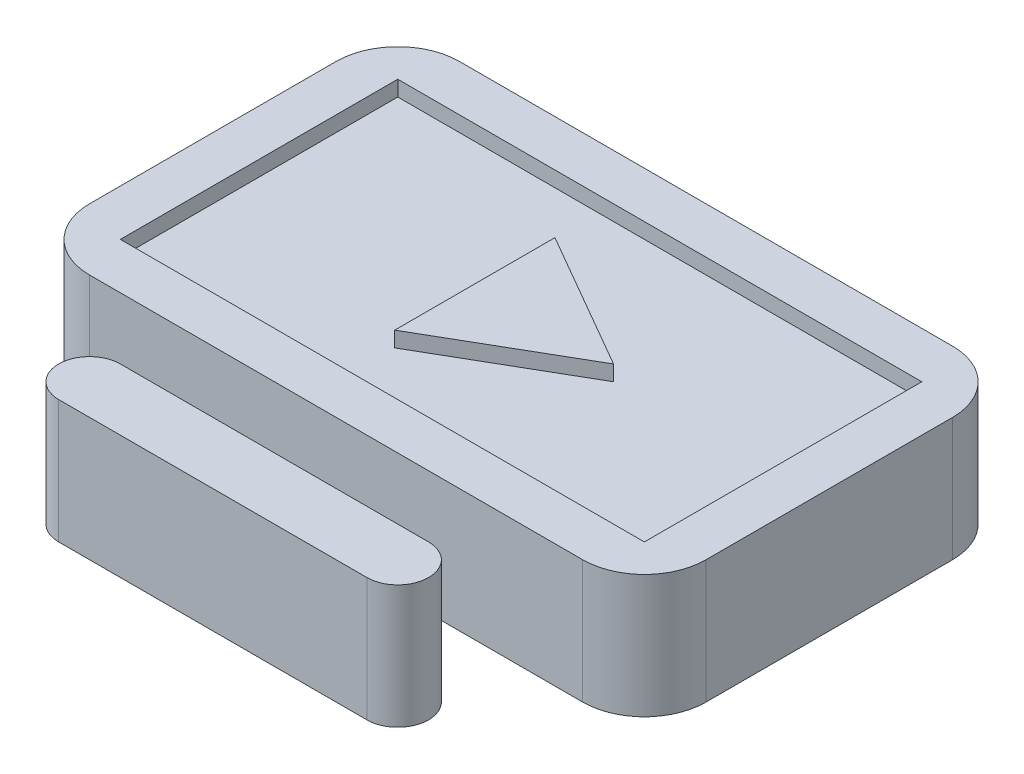
from build123d import *

# Parameters (mm, degrees)
BOSS_EXTRUDE1_DEPTH = 50.8
FILLET1_R           = 25.4
SKETCH4_W           = 215.9
SKETCH4_H           = 114.3
CUT_EXTRUDE1_DEPTH  = 6.35
BOSS_EXTRUDE2_DEPTH = 6.35
SKETCH6_W           = 25.4
SKETCH6_H           = 25.4
CUT_EXTRUDE2_DEPTH  = 25.4


with BuildPart() as part:
    # Sketch2 → Boss-Extrude1 (new body)
    with BuildSketch(Plane(origin=(0, 0, 0), x_dir=(1, 0, 0), z_dir=(0, 1, 0))):
        with BuildLine():
            Line((-12.7, 12.7), (-63.5, 12.7))
            ThreePointArc((-63.5, 12.7), (-76.2, 0), (-63.5, -12.7))
            Line((-63.5, -12.7), (63.5, -12.7))
            ThreePointArc((63.5, -12.7), (76.2, 0), (63.5, 12.7))
            Line((63.5, 12.7), (12.7, 12.7))
            Line((12.7, 12.7), (12.7, 38.1))
            Line((12.7, 38.1), (127, 38.1))
            Line((127, 38.1), (127, 190.5))
            Line((127, 190.5), (-127, 190.5))
            Line((-127, 190.5), (-127, 38.1))
            Line((-127, 38.1), (-12.7, 38.1))
            Line((-12.7, 38.1), (-12.7, 12.7))
        make_face()
    extrude(amount=BOSS_EXTRUDE1_DEPTH)

    # Fillet1
    fillet1_edges = [part.edges().sort_by_distance(p)[0] for p in [
        (127, 25.4, -38.1),
        (-127, 25.4, -38.1),
        (-127, 25.4, -190.5),
        (127, 25.4, -190.5),
    ]]
    fillet(fillet1_edges, radius=FILLET1_R)

    # Sketch4 → Cut-Extrude1 (cut)
    with BuildSketch(Plane(origin=(0, 50.8, 0), x_dir=(1, 0, 0), z_dir=(0, 1, 0))):
        with Locations((0, 114.3)):
            Rectangle(SKETCH4_W, SKETCH4_H)
    extrude(amount=-CUT_EXTRUDE1_DEPTH, mode=Mode.SUBTRACT)

    # Sketch5 → Boss-Extrude2 (add)
    with BuildSketch(Plane(origin=(0, 44.45, 0), x_dir=(1, 0, 0), z_dir=(0, 1, 0))):
        Polygon((38.1, 114.3), (-19.05, 147.295567884), (-19.05, 81.304432116), align=None)
    extrude(amount=BOSS_EXTRUDE2_DEPTH)

    # Sketch6 → Cut-Extrude2 (cut)
    with BuildSketch(Plane(origin=(0, 50.8, 0), x_dir=(1, 0, 0), z_dir=(0, 1, 0))):
        with Locations((0, 25.4)):
            Rectangle(SKETCH6_W, SKETCH6_H)
    extrude(amount=-CUT_EXTRUDE2_DEPTH, mode=Mode.SUBTRACT)


solid = part.part
